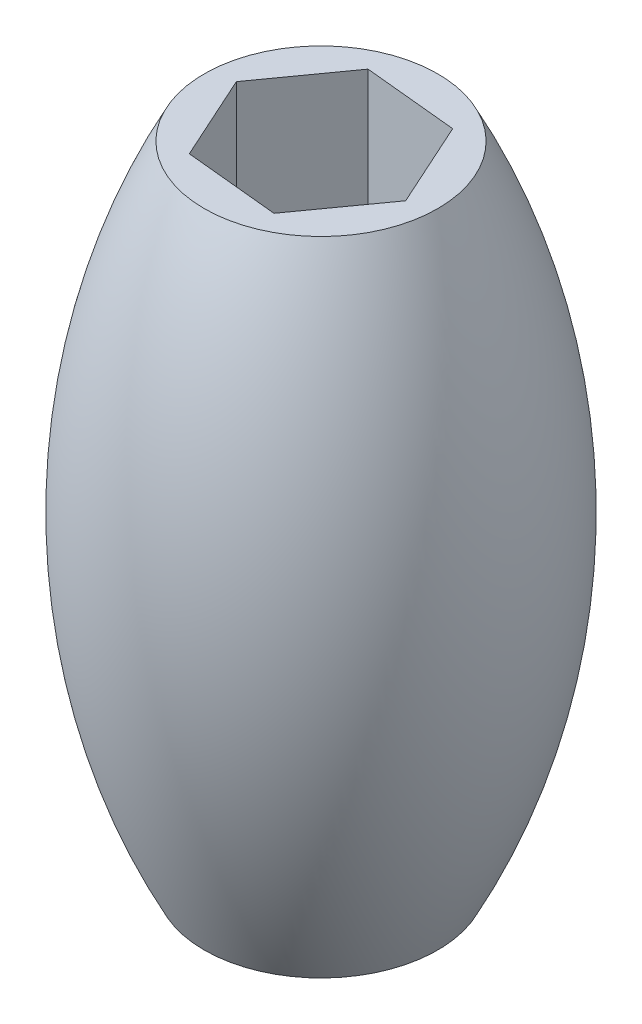
from build123d import *

# Parameters (mm, degrees)
SKETCH1_R           = 19.05
BOSS_EXTRUDE1_DEPTH = 104.775
CUT_EXTRUDE1_DEPTH  = 104.775


with BuildPart() as part:
    # Sketch1 → Boss-Extrude1 (new body)
    with BuildSketch(Plane(origin=(0, 0, 0), x_dir=(1, 0, 0), z_dir=(0, 1, 0))):
        Circle(SKETCH1_R)
    extrude(amount=BOSS_EXTRUDE1_DEPTH)

    # Sketch2 → Cut-Extrude1 (cut)
    with BuildSketch(Plane.XZ):
        Polygon((-15.323636661, -1.510781079), (-6.353443536, -14.026049167), (8.970193125, -12.515268087), (15.323636661, 1.510781079), (6.353443536, 14.026049167), (-8.970193125, 12.515268087), align=None)
    extrude(amount=-CUT_EXTRUDE1_DEPTH, mode=Mode.SUBTRACT)

    # Sketch4 → Revolve1 (revolve)
    with BuildSketch(Plane.XY):
        with BuildLine():
            Line((-19.05, 104.775), (-19.05, 0))
            ThreePointArc((-19.05, 0), (-31.75, 52.3875), (-19.05, 104.775))
        make_face()
    revolve(axis=Axis((0, 0, 0), (0, 1, 0)))


solid = part.part
